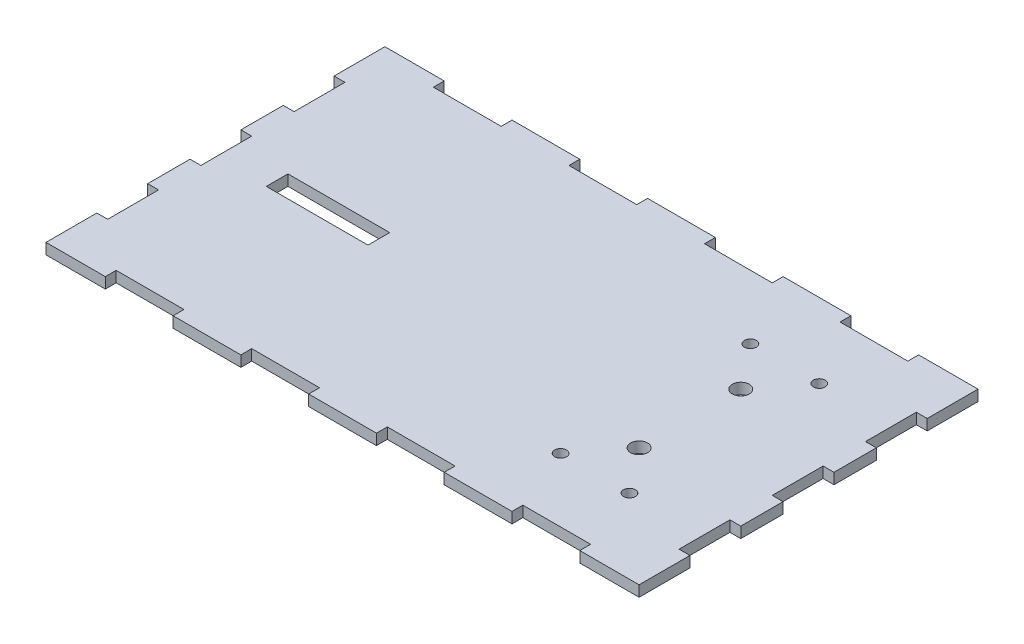
from build123d import *

# Parameters (mm, degrees)
SKETCH1_R           = 2.5
SKETCH1_R_2         = 1.75
SKETCH1_W           = 30
SKETCH1_H           = 6.4
BOSS_EXTRUDE1_DEPTH = 3.2


with BuildPart() as part:
    # Sketch1 → Boss-Extrude1 (new body)
    with BuildSketch(Plane(origin=(0, 0, 0), x_dir=(1, 0, 0), z_dir=(0, 1, 0))):
        Polygon((-87.5, 7.5), (-87.5, 20), (-84.3, 20), (-84.3, 35), (-87.5, 35), (-87.5, 50), (-70, 50), (-70, 46.8), (-50, 46.8), (-50, 50), (-30, 50), (-30, 46.8), (-10, 46.8), (-10, 50), (10, 50), (10, 46.8), (30, 46.8), (30, 50), (50, 50), (50, 46.8), (70, 46.8), (70, 50), (87.5, 50), (87.5, 35), (84.3, 35), (84.3, 20), (87.5, 20), (87.5, 7.5), (84.3, 7.5), (84.3, -7.5), (87.5, -7.5), (87.5, -20), (84.3, -20), (84.3, -35), (87.5, -35), (87.5, -50), (70, -50), (70, -46.8), (50, -46.8), (50, -50), (30, -50), (30, -46.8), (10, -46.8), (10, -50), (-10, -50), (-10, -46.8), (-30, -46.8), (-30, -50), (-50, -50), (-50, -46.8), (-70, -46.8), (-70, -50), (-87.5, -50), (-87.5, -35), (-84.3, -35), (-84.3, -20), (-87.5, -20), (-87.5, -7.5), (-84.3, -7.5), (-84.3, 7.5), align=None)
        with Locations((52.5, 15)):
            Circle(SKETCH1_R, mode=Mode.SUBTRACT)
        with Locations((42.34, 28)):
            Circle(SKETCH1_R_2, mode=Mode.SUBTRACT)
        with Locations((62.66, 28)):
            Circle(SKETCH1_R_2, mode=Mode.SUBTRACT)
        with Locations((62.66, -28)):
            Circle(SKETCH1_R_2, mode=Mode.SUBTRACT)
        with Locations((42.34, -28)):
            Circle(SKETCH1_R_2, mode=Mode.SUBTRACT)
        with Locations((52.5, -15)):
            Circle(SKETCH1_R, mode=Mode.SUBTRACT)
        with Locations((-54.3, 0)):
            Rectangle(SKETCH1_W, SKETCH1_H, mode=Mode.SUBTRACT)
    extrude(amount=BOSS_EXTRUDE1_DEPTH)


solid = part.part
